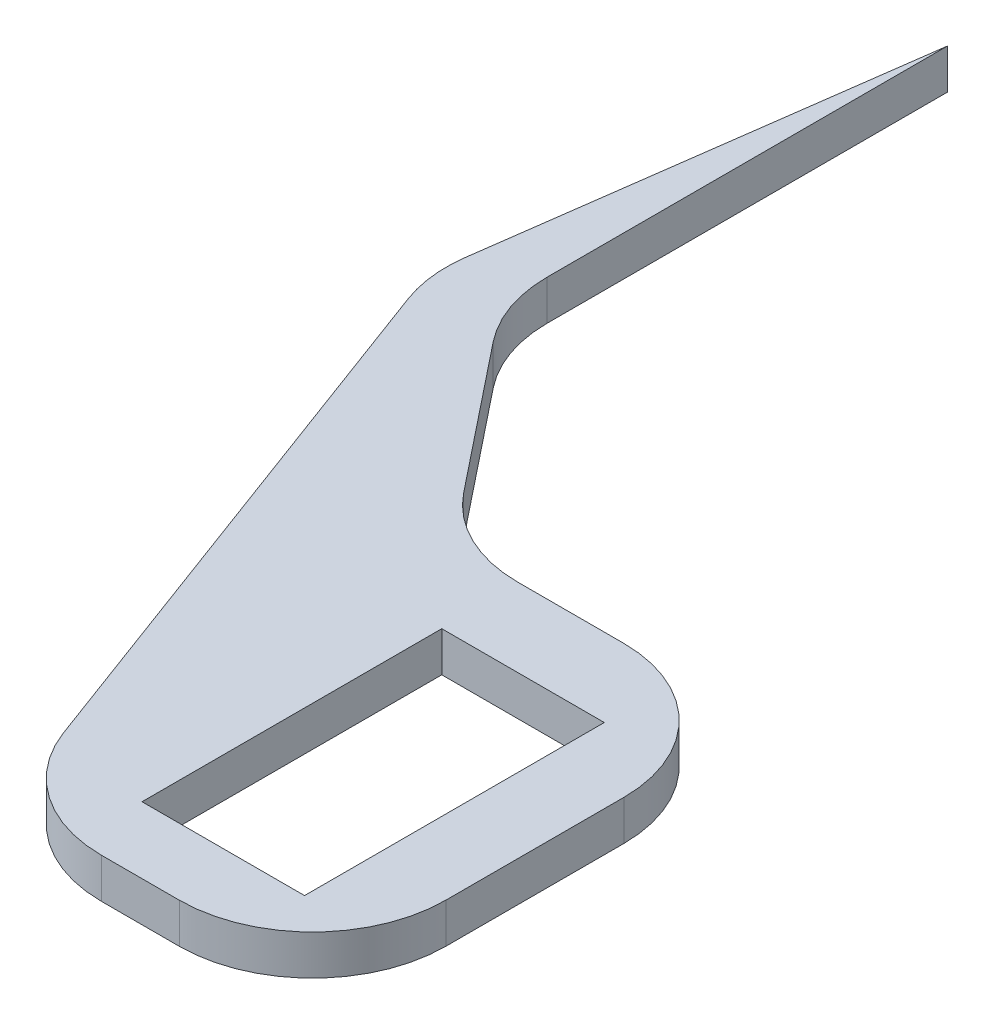
from build123d import *

# Parameters (mm, degrees)
SKETCH1_W           = 12.2
SKETCH1_H           = 22.5
BOSS_EXTRUDE1_DEPTH = 3
FILLET2_R           = 10


with BuildPart() as part:
    # Sketch1 → Boss-Extrude1 (new body)
    with BuildSketch(Plane(origin=(0, 0, 0), x_dir=(1, 0, 0), z_dir=(0, 1, 0))):
        Polygon((-11.1, -16.25), (11.7, -16.25), (11.7, 17.128517662), (-11.1, 17.128517662), (-25, 34.565348469), (-25, 68.106999691), (-29.68539708, 33.799719695), align=None)
        Rectangle(SKETCH1_W, SKETCH1_H, mode=Mode.SUBTRACT)
    extrude(amount=BOSS_EXTRUDE1_DEPTH)

    # Fillet2
    fillet2_edges = [part.edges().sort_by_distance(p)[0] for p in [
        (11.7, 1.5, 16.25),
        (-11.1, 1.5, 16.25),
        (-29.68539708, 1.5, -33.799719695),
        (-25, 1.5, -34.565348469),
        (-11.1, 1.5, -17.128517662),
        (11.7, 1.5, -17.128517662),
    ]]
    fillet(fillet2_edges, radius=FILLET2_R)


solid = part.part
